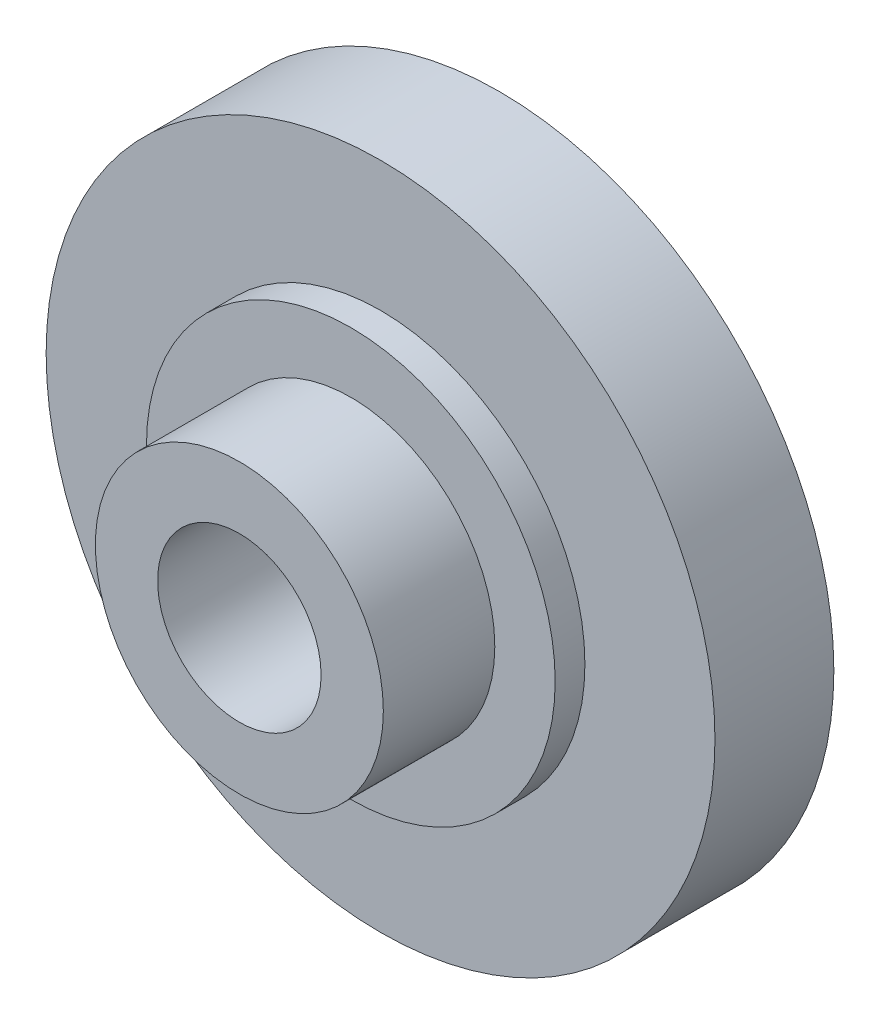
from build123d import *

# Parameters (mm, degrees)
SKETCH1_R           = 9
SKETCH1_R_2         = 2.2
BOSS_EXTRUDE1_DEPTH = 7
SKETCH2_R           = 9
SKETCH2_R_2         = 5.5
CUT_EXTRUDE1_DEPTH  = 3.8
SKETCH3_R           = 5.5
SKETCH3_R_2         = 3.875
CUT_EXTRUDE2_DEPTH  = 3


with BuildPart() as part:
    # Sketch1 → Boss-Extrude1 (new body)
    with BuildSketch(Plane.XY):
        Circle(SKETCH1_R)
        Circle(SKETCH1_R_2, mode=Mode.SUBTRACT)
    extrude(amount=BOSS_EXTRUDE1_DEPTH)

    # Sketch2 → Cut-Extrude1 (cut)
    with BuildSketch(Plane.XY.offset(7)):
        Circle(SKETCH2_R)
        Circle(SKETCH2_R_2, mode=Mode.SUBTRACT)
    extrude(amount=-CUT_EXTRUDE1_DEPTH, mode=Mode.SUBTRACT)

    # Sketch3 → Cut-Extrude2 (cut)
    with BuildSketch(Plane.XY.offset(7)):
        Circle(SKETCH3_R)
        Circle(SKETCH3_R_2, mode=Mode.SUBTRACT)
    extrude(amount=-CUT_EXTRUDE2_DEPTH, mode=Mode.SUBTRACT)


solid = part.part
